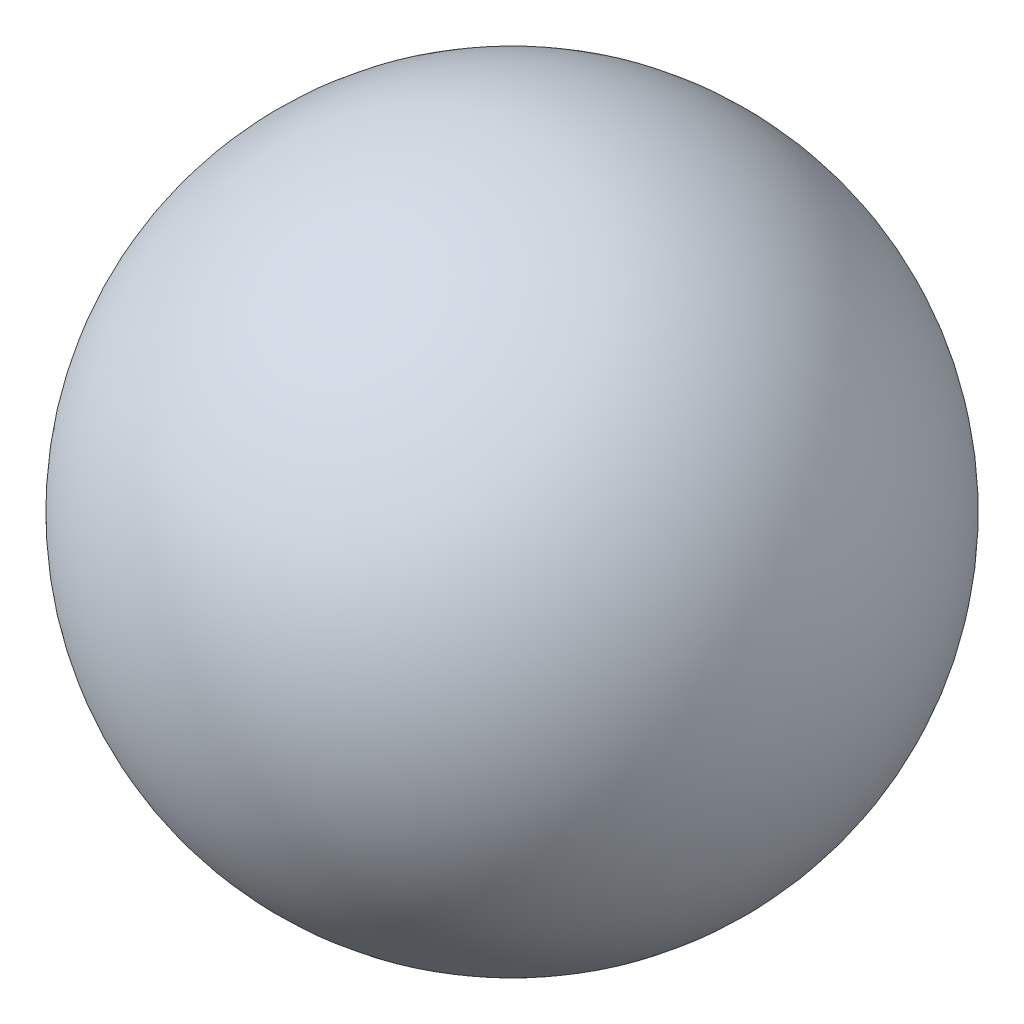
from build123d import *


with BuildPart() as part:
    # Esquisse2 → Révolution1 (revolve)
    with BuildSketch(Plane.XY):
        with BuildLine():
            Line((0, 32.5), (0, -32.5))
            ThreePointArc((0, -32.5), (32.5, 0), (0, 32.5))
        make_face()
    revolve(axis=Axis((0, 43.738322769, 0), (0, -1, 0)))


solid = part.part
